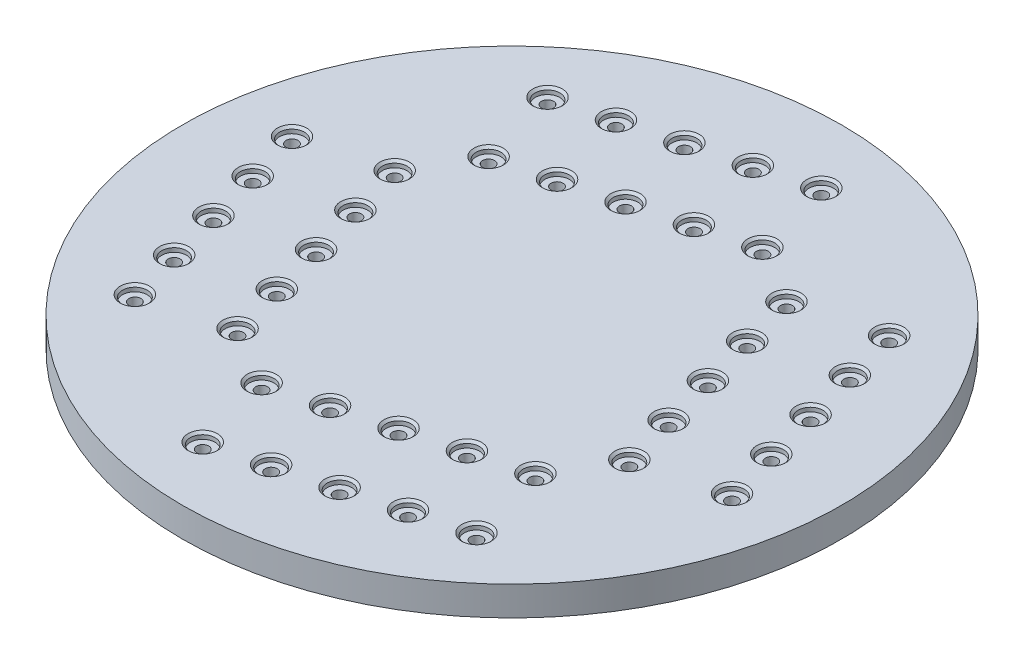
from build123d import *

# Parameters (mm, degrees)
SKETCH1_R                                   = 90
BOSS_EXTRUDE1_DEPTH                         = 8
CBORE_FOR_4_BINDING_HEAD_MACHINE_SC_2_COUNT = 2
CBORE_FOR_4_BINDING_HEAD_MACHINE_SC_2_PITCH = 22.86
LPATTERN1_COUNT                             = 5
LPATTERN1_PITCH                             = 15.24
CIRPATTERN1_COUNT                           = 4


with BuildPart() as part:
    # Sketch1 → Boss-Extrude1 (new body)
    with BuildSketch(Plane(origin=(0, 0, 0), x_dir=(1, 0, 0), z_dir=(0, 1, 0))):
        with Locations((-69.046652583, 32.618591048)):
            Circle(SKETCH1_R)
    extrude(amount=BOSS_EXTRUDE1_DEPTH)

    # Sketch11 → CBORE for #4 Binding Head Machine Screw2 (revolve, cut)
    with BuildSketch(Plane(origin=(-81.240520583, 8, 39.657230567), x_dir=(0, 0, 1), z_dir=(1, 0, 0))):
        Polygon((0, 0), (0, 8), (1.63195, 8), (1.63195, 1.7272), (3.37312, 1.7272), (3.37312, 0.635), (4.00812, 0), align=None)
    cbore_for_4_binding_head_machine_screw2 = revolve(axis=Axis((-81.240520583, 14.35, 39.657230567), (0, -1, 0)), mode=Mode.SUBTRACT)

    # CBORE for _4 Binding Head Machine Sc 2: CBORE for #4 Binding Head Machine Screw2 ×2
    with Locations(*[Vector(-0.261335617, 0, -0.965247997) * (i * CBORE_FOR_4_BINDING_HEAD_MACHINE_SC_2_PITCH) for i in range(1, CBORE_FOR_4_BINDING_HEAD_MACHINE_SC_2_COUNT)]):
        add(cbore_for_4_binding_head_machine_screw2, mode=Mode.SUBTRACT)

    # LPattern1: CBORE for #4 Binding Head Machine Screw2 ×5
    with Locations(*[Vector(0.965247997, 0, -0.261335617) * (i * LPATTERN1_PITCH) for i in range(1, LPATTERN1_COUNT)]):
        add(cbore_for_4_binding_head_machine_screw2, mode=Mode.SUBTRACT)

    # LPattern1 copy 1 sketch → LPattern1 copy 1 (revolve, cut)
    with BuildSketch(Plane(origin=(-72.504273327, 8, 13.608906554), x_dir=(0, 0, 1), z_dir=(1, 0, 0))):
        Polygon((0, 0), (0, 8), (1.63195, 8), (1.63195, 1.7272), (3.37312, 1.7272), (3.37312, 0.635), (4.00812, 0), align=None)
    revolve(axis=Axis((-72.504273327, 14.35, 13.608906554), (0, -1, 0)), mode=Mode.SUBTRACT)

    # LPattern1 copy 2 sketch → LPattern1 copy 2 (revolve, cut)
    with BuildSketch(Plane(origin=(-57.793893858, 8, 9.626151746), x_dir=(0, 0, 1), z_dir=(1, 0, 0))):
        Polygon((0, 0), (0, 8), (1.63195, 8), (1.63195, 1.7272), (3.37312, 1.7272), (3.37312, 0.635), (4.00812, 0), align=None)
    revolve(axis=Axis((-57.793893858, 14.35, 9.626151746), (0, -1, 0)), mode=Mode.SUBTRACT)

    # LPattern1 copy 3 sketch → LPattern1 copy 3 (revolve, cut)
    with BuildSketch(Plane(origin=(-43.083514389, 8, 5.643396937), x_dir=(0, 0, 1), z_dir=(1, 0, 0))):
        Polygon((0, 0), (0, 8), (1.63195, 8), (1.63195, 1.7272), (3.37312, 1.7272), (3.37312, 0.635), (4.00812, 0), align=None)
    revolve(axis=Axis((-43.083514389, 14.35, 5.643396937), (0, -1, 0)), mode=Mode.SUBTRACT)

    # LPattern1 copy 4 sketch → LPattern1 copy 4 (revolve, cut)
    with BuildSketch(Plane(origin=(-28.373134919, 8, 1.660642128), x_dir=(0, 0, 1), z_dir=(1, 0, 0))):
        Polygon((0, 0), (0, 8), (1.63195, 8), (1.63195, 1.7272), (3.37312, 1.7272), (3.37312, 0.635), (4.00812, 0), align=None)
    revolve(axis=Axis((-28.373134919, 14.35, 1.660642128), (0, -1, 0)), mode=Mode.SUBTRACT)

    # CirPattern1: CBORE for #4 Binding Head Machine Screw2 ×4 about axis
    cirpattern1_axis = Axis((-69.046652583, 0, -32.618591048), (0, 1, 0))
    for i in range(1, CIRPATTERN1_COUNT):
        add(cbore_for_4_binding_head_machine_screw2.rotate(cirpattern1_axis, i * 360 / CIRPATTERN1_COUNT), mode=Mode.SUBTRACT)

    # CirPattern1 copy 1 sketch → CirPattern1 copy 1 (revolve, cut)
    with BuildSketch(Plane(origin=(-0.753585777, 8, -35.135102517), x_dir=(1, 0, 0), z_dir=(0, 0, -1))):
        Polygon((0, 0), (0, 8), (1.63195, 8), (1.63195, 1.7272), (3.37312, 1.7272), (3.37312, 0.635), (4.00812, 0), align=None)
    revolve(axis=Axis((-0.753585777, 14.35, -35.135102517), (0, -1, 0)), mode=Mode.SUBTRACT)

    # CirPattern1 copy 2 sketch → CirPattern1 copy 2 (revolve, cut)
    with BuildSketch(Plane(origin=(-71.563164052, 8, -100.911657854), x_dir=(0, 0, -1), z_dir=(-1, 0, 0))):
        Polygon((0, 0), (0, 8), (1.63195, 8), (1.63195, 1.7272), (3.37312, 1.7272), (3.37312, 0.635), (4.00812, 0), align=None)
    revolve(axis=Axis((-71.563164052, 14.35, -100.911657854), (0, -1, 0)), mode=Mode.SUBTRACT)

    # CirPattern1 copy 3 sketch → CirPattern1 copy 3 (revolve, cut)
    with BuildSketch(Plane(origin=(-137.339719389, 8, -30.102079579), x_dir=(-1, 0, 0), z_dir=(0, 0, 1))):
        Polygon((0, 0), (0, 8), (1.63195, 8), (1.63195, 1.7272), (3.37312, 1.7272), (3.37312, 0.635), (4.00812, 0), align=None)
    revolve(axis=Axis((-137.339719389, 14.35, -30.102079579), (0, -1, 0)), mode=Mode.SUBTRACT)

    # CirPattern1 copy 4 sketch → CirPattern1 copy 4 (revolve, cut)
    with BuildSketch(Plane(origin=(-4.736340586, 8, -49.845481986), x_dir=(1, 0, 0), z_dir=(0, 0, -1))):
        Polygon((0, 0), (0, 8), (1.63195, 8), (1.63195, 1.7272), (3.37312, 1.7272), (3.37312, 0.635), (4.00812, 0), align=None)
    revolve(axis=Axis((-4.736340586, 14.35, -49.845481986), (0, -1, 0)), mode=Mode.SUBTRACT)

    # CirPattern1 copy 5 sketch → CirPattern1 copy 5 (revolve, cut)
    with BuildSketch(Plane(origin=(-86.273543521, 8, -96.928903045), x_dir=(0, 0, -1), z_dir=(-1, 0, 0))):
        Polygon((0, 0), (0, 8), (1.63195, 8), (1.63195, 1.7272), (3.37312, 1.7272), (3.37312, 0.635), (4.00812, 0), align=None)
    revolve(axis=Axis((-86.273543521, 14.35, -96.928903045), (0, -1, 0)), mode=Mode.SUBTRACT)

    # CirPattern1 copy 6 sketch → CirPattern1 copy 6 (revolve, cut)
    with BuildSketch(Plane(origin=(-133.35696458, 8, -15.39170011), x_dir=(-1, 0, 0), z_dir=(0, 0, 1))):
        Polygon((0, 0), (0, 8), (1.63195, 8), (1.63195, 1.7272), (3.37312, 1.7272), (3.37312, 0.635), (4.00812, 0), align=None)
    revolve(axis=Axis((-133.35696458, 14.35, -15.39170011), (0, -1, 0)), mode=Mode.SUBTRACT)

    # CirPattern1 copy 7 sketch → CirPattern1 copy 7 (revolve, cut)
    with BuildSketch(Plane(origin=(-8.719095395, 8, -64.555861455), x_dir=(1, 0, 0), z_dir=(0, 0, -1))):
        Polygon((0, 0), (0, 8), (1.63195, 8), (1.63195, 1.7272), (3.37312, 1.7272), (3.37312, 0.635), (4.00812, 0), align=None)
    revolve(axis=Axis((-8.719095395, 14.35, -64.555861455), (0, -1, 0)), mode=Mode.SUBTRACT)

    # CirPattern1 copy 8 sketch → CirPattern1 copy 8 (revolve, cut)
    with BuildSketch(Plane(origin=(-100.983922991, 8, -92.946148236), x_dir=(0, 0, -1), z_dir=(-1, 0, 0))):
        Polygon((0, 0), (0, 8), (1.63195, 8), (1.63195, 1.7272), (3.37312, 1.7272), (3.37312, 0.635), (4.00812, 0), align=None)
    revolve(axis=Axis((-100.983922991, 14.35, -92.946148236), (0, -1, 0)), mode=Mode.SUBTRACT)

    # CirPattern1 copy 9 sketch → CirPattern1 copy 9 (revolve, cut)
    with BuildSketch(Plane(origin=(-129.374209771, 8, -0.68132064), x_dir=(-1, 0, 0), z_dir=(0, 0, 1))):
        Polygon((0, 0), (0, 8), (1.63195, 8), (1.63195, 1.7272), (3.37312, 1.7272), (3.37312, 0.635), (4.00812, 0), align=None)
    revolve(axis=Axis((-129.374209771, 14.35, -0.68132064), (0, -1, 0)), mode=Mode.SUBTRACT)

    # CirPattern1 copy 10 sketch → CirPattern1 copy 10 (revolve, cut)
    with BuildSketch(Plane(origin=(-12.701850203, 8, -79.266240925), x_dir=(1, 0, 0), z_dir=(0, 0, -1))):
        Polygon((0, 0), (0, 8), (1.63195, 8), (1.63195, 1.7272), (3.37312, 1.7272), (3.37312, 0.635), (4.00812, 0), align=None)
    revolve(axis=Axis((-12.701850203, 14.35, -79.266240925), (0, -1, 0)), mode=Mode.SUBTRACT)

    # CirPattern1 copy 11 sketch → CirPattern1 copy 11 (revolve, cut)
    with BuildSketch(Plane(origin=(-115.69430246, 8, -88.963393427), x_dir=(0, 0, -1), z_dir=(-1, 0, 0))):
        Polygon((0, 0), (0, 8), (1.63195, 8), (1.63195, 1.7272), (3.37312, 1.7272), (3.37312, 0.635), (4.00812, 0), align=None)
    revolve(axis=Axis((-115.69430246, 14.35, -88.963393427), (0, -1, 0)), mode=Mode.SUBTRACT)

    # CirPattern1 copy 12 sketch → CirPattern1 copy 12 (revolve, cut)
    with BuildSketch(Plane(origin=(-125.391454962, 8, 14.029058829), x_dir=(-1, 0, 0), z_dir=(0, 0, 1))):
        Polygon((0, 0), (0, 8), (1.63195, 8), (1.63195, 1.7272), (3.37312, 1.7272), (3.37312, 0.635), (4.00812, 0), align=None)
    revolve(axis=Axis((-125.391454962, 14.35, 14.029058829), (0, -1, 0)), mode=Mode.SUBTRACT)

    # CirPattern1 copy 13 sketch → CirPattern1 copy 13 (revolve, cut)
    with BuildSketch(Plane(origin=(-22.819154981, 8, -29.160970303), x_dir=(1, 0, 0), z_dir=(0, 0, -1))):
        Polygon((0, 0), (0, 8), (1.63195, 8), (1.63195, 1.7272), (3.37312, 1.7272), (3.37312, 0.635), (4.00812, 0), align=None)
    revolve(axis=Axis((-22.819154981, 14.35, -29.160970303), (0, -1, 0)), mode=Mode.SUBTRACT)

    # CirPattern1 copy 14 sketch → CirPattern1 copy 14 (revolve, cut)
    with BuildSketch(Plane(origin=(-65.589031838, 8, -78.84608865), x_dir=(0, 0, -1), z_dir=(-1, 0, 0))):
        Polygon((0, 0), (0, 8), (1.63195, 8), (1.63195, 1.7272), (3.37312, 1.7272), (3.37312, 0.635), (4.00812, 0), align=None)
    revolve(axis=Axis((-65.589031838, 14.35, -78.84608865), (0, -1, 0)), mode=Mode.SUBTRACT)

    # CirPattern1 copy 15 sketch → CirPattern1 copy 15 (revolve, cut)
    with BuildSketch(Plane(origin=(-115.274150185, 8, -36.076211792), x_dir=(-1, 0, 0), z_dir=(0, 0, 1))):
        Polygon((0, 0), (0, 8), (1.63195, 8), (1.63195, 1.7272), (3.37312, 1.7272), (3.37312, 0.635), (4.00812, 0), align=None)
    revolve(axis=Axis((-115.274150185, 14.35, -36.076211792), (0, -1, 0)), mode=Mode.SUBTRACT)

    # CirPattern1 copy 16 sketch → CirPattern1 copy 16 (revolve, cut)
    with BuildSketch(Plane(origin=(-26.80190979, 8, -43.871349773), x_dir=(1, 0, 0), z_dir=(0, 0, -1))):
        Polygon((0, 0), (0, 8), (1.63195, 8), (1.63195, 1.7272), (3.37312, 1.7272), (3.37312, 0.635), (4.00812, 0), align=None)
    revolve(axis=Axis((-26.80190979, 14.35, -43.871349773), (0, -1, 0)), mode=Mode.SUBTRACT)

    # CirPattern1 copy 17 sketch → CirPattern1 copy 17 (revolve, cut)
    with BuildSketch(Plane(origin=(-80.299411308, 8, -74.863333841), x_dir=(0, 0, -1), z_dir=(-1, 0, 0))):
        Polygon((0, 0), (0, 8), (1.63195, 8), (1.63195, 1.7272), (3.37312, 1.7272), (3.37312, 0.635), (4.00812, 0), align=None)
    revolve(axis=Axis((-80.299411308, 14.35, -74.863333841), (0, -1, 0)), mode=Mode.SUBTRACT)

    # CirPattern1 copy 18 sketch → CirPattern1 copy 18 (revolve, cut)
    with BuildSketch(Plane(origin=(-111.291395376, 8, -21.365832323), x_dir=(-1, 0, 0), z_dir=(0, 0, 1))):
        Polygon((0, 0), (0, 8), (1.63195, 8), (1.63195, 1.7272), (3.37312, 1.7272), (3.37312, 0.635), (4.00812, 0), align=None)
    revolve(axis=Axis((-111.291395376, 14.35, -21.365832323), (0, -1, 0)), mode=Mode.SUBTRACT)

    # CirPattern1 copy 19 sketch → CirPattern1 copy 19 (revolve, cut)
    with BuildSketch(Plane(origin=(-30.784664599, 8, -58.581729242), x_dir=(1, 0, 0), z_dir=(0, 0, -1))):
        Polygon((0, 0), (0, 8), (1.63195, 8), (1.63195, 1.7272), (3.37312, 1.7272), (3.37312, 0.635), (4.00812, 0), align=None)
    revolve(axis=Axis((-30.784664599, 14.35, -58.581729242), (0, -1, 0)), mode=Mode.SUBTRACT)

    # CirPattern1 copy 20 sketch → CirPattern1 copy 20 (revolve, cut)
    with BuildSketch(Plane(origin=(-95.009790777, 8, -70.880579032), x_dir=(0, 0, -1), z_dir=(-1, 0, 0))):
        Polygon((0, 0), (0, 8), (1.63195, 8), (1.63195, 1.7272), (3.37312, 1.7272), (3.37312, 0.635), (4.00812, 0), align=None)
    revolve(axis=Axis((-95.009790777, 14.35, -70.880579032), (0, -1, 0)), mode=Mode.SUBTRACT)

    # CirPattern1 copy 21 sketch → CirPattern1 copy 21 (revolve, cut)
    with BuildSketch(Plane(origin=(-107.308640567, 8, -6.655452854), x_dir=(-1, 0, 0), z_dir=(0, 0, 1))):
        Polygon((0, 0), (0, 8), (1.63195, 8), (1.63195, 1.7272), (3.37312, 1.7272), (3.37312, 0.635), (4.00812, 0), align=None)
    revolve(axis=Axis((-107.308640567, 14.35, -6.655452854), (0, -1, 0)), mode=Mode.SUBTRACT)

    # CirPattern1 copy 22 sketch → CirPattern1 copy 22 (revolve, cut)
    with BuildSketch(Plane(origin=(-34.767419407, 8, -73.292108711), x_dir=(1, 0, 0), z_dir=(0, 0, -1))):
        Polygon((0, 0), (0, 8), (1.63195, 8), (1.63195, 1.7272), (3.37312, 1.7272), (3.37312, 0.635), (4.00812, 0), align=None)
    revolve(axis=Axis((-34.767419407, 14.35, -73.292108711), (0, -1, 0)), mode=Mode.SUBTRACT)

    # CirPattern1 copy 23 sketch → CirPattern1 copy 23 (revolve, cut)
    with BuildSketch(Plane(origin=(-109.720170246, 8, -66.897824223), x_dir=(0, 0, -1), z_dir=(-1, 0, 0))):
        Polygon((0, 0), (0, 8), (1.63195, 8), (1.63195, 1.7272), (3.37312, 1.7272), (3.37312, 0.635), (4.00812, 0), align=None)
    revolve(axis=Axis((-109.720170246, 14.35, -66.897824223), (0, -1, 0)), mode=Mode.SUBTRACT)

    # CirPattern1 copy 24 sketch → CirPattern1 copy 24 (revolve, cut)
    with BuildSketch(Plane(origin=(-103.325885758, 8, 8.054926616), x_dir=(-1, 0, 0), z_dir=(0, 0, 1))):
        Polygon((0, 0), (0, 8), (1.63195, 8), (1.63195, 1.7272), (3.37312, 1.7272), (3.37312, 0.635), (4.00812, 0), align=None)
    revolve(axis=Axis((-103.325885758, 14.35, 8.054926616), (0, -1, 0)), mode=Mode.SUBTRACT)

    # CirPattern1 copy 25 sketch → CirPattern1 copy 25 (revolve, cut)
    with BuildSketch(Plane(origin=(-18.836400172, 8, -14.450590834), x_dir=(1, 0, 0), z_dir=(0, 0, -1))):
        Polygon((0, 0), (0, 8), (1.63195, 8), (1.63195, 1.7272), (3.37312, 1.7272), (3.37312, 0.635), (4.00812, 0), align=None)
    revolve(axis=Axis((-18.836400172, 14.35, -14.450590834), (0, -1, 0)), mode=Mode.SUBTRACT)

    # CirPattern1 copy 26 sketch → CirPattern1 copy 26 (revolve, cut)
    with BuildSketch(Plane(origin=(-50.878652369, 8, -82.828843459), x_dir=(0, 0, -1), z_dir=(-1, 0, 0))):
        Polygon((0, 0), (0, 8), (1.63195, 8), (1.63195, 1.7272), (3.37312, 1.7272), (3.37312, 0.635), (4.00812, 0), align=None)
    revolve(axis=Axis((-50.878652369, 14.35, -82.828843459), (0, -1, 0)), mode=Mode.SUBTRACT)

    # CirPattern1 copy 27 sketch → CirPattern1 copy 27 (revolve, cut)
    with BuildSketch(Plane(origin=(-119.256904994, 8, -50.786591262), x_dir=(-1, 0, 0), z_dir=(0, 0, 1))):
        Polygon((0, 0), (0, 8), (1.63195, 8), (1.63195, 1.7272), (3.37312, 1.7272), (3.37312, 0.635), (4.00812, 0), align=None)
    revolve(axis=Axis((-119.256904994, 14.35, -50.786591262), (0, -1, 0)), mode=Mode.SUBTRACT)


solid = part.part
